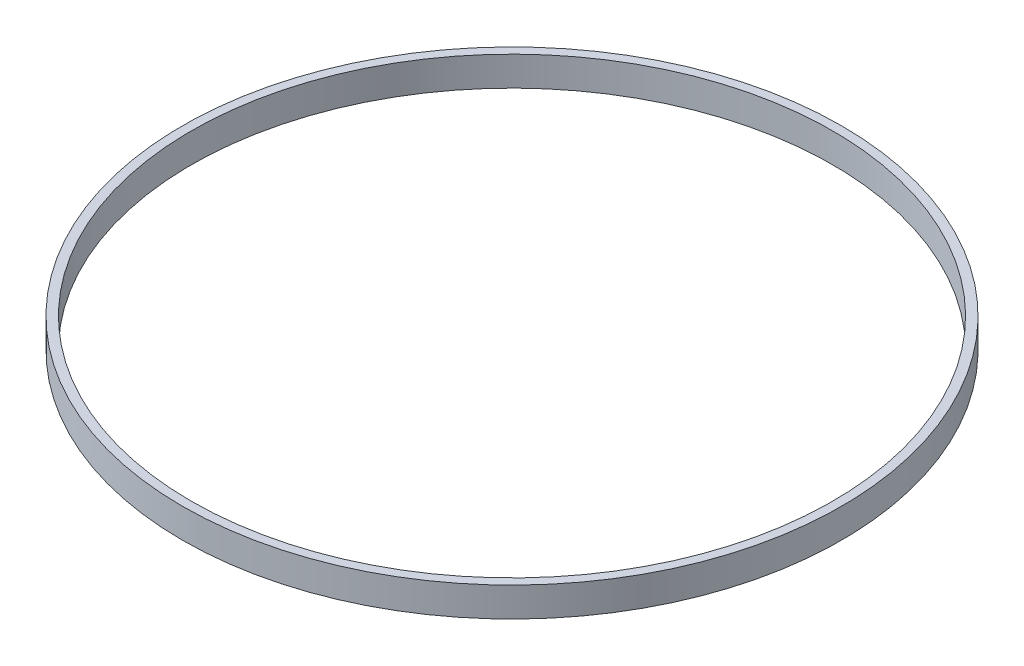
from build123d import *

# Parameters (mm, degrees)
SKETCH1_R           = 28
SKETCH1_R_2         = 27.25
BOSS_EXTRUDE1_DEPTH = 2.5


with BuildPart() as part:
    # Sketch1 → Boss-Extrude1 (new body)
    with BuildSketch(Plane(origin=(0, 0, 0), x_dir=(1, 0, 0), z_dir=(0, 1, 0))):
        Circle(SKETCH1_R)
        Circle(SKETCH1_R_2, mode=Mode.SUBTRACT)
    extrude(amount=BOSS_EXTRUDE1_DEPTH)


solid = part.part
